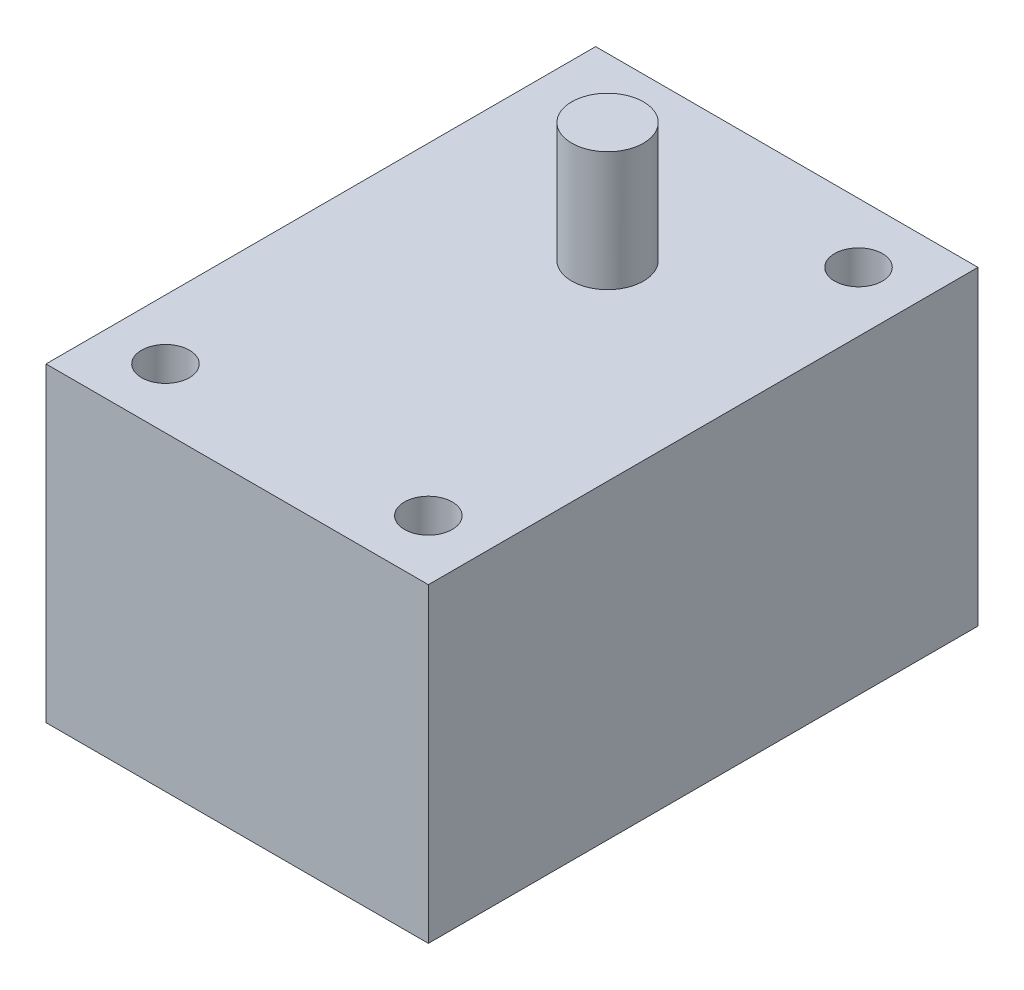
from build123d import *

# Parameters (mm, degrees)
SKETCH2_W            = 32
SKETCH2_H            = 26
BASE_DEPTH           = 46
SKETCH3_R            = 2
MOUNTING_HOLES_DEPTH = 10
SKETCH4_R            = 3
AXLE_DEPTH           = 10


with BuildPart() as part:
    # Sketch2 → base (new body)
    with BuildSketch(Plane.XY):
        with Locations((16, 13)):
            Rectangle(SKETCH2_W, SKETCH2_H)
    extrude(amount=BASE_DEPTH)

    # Sketch3 → mounting holes (cut)
    with BuildSketch(Plane(origin=(0, 26, 0), x_dir=(1, 0, 0), z_dir=(0, 1, 0))):
        with Locations((5, -5)):
            Circle(SKETCH3_R)
        with Locations((27, -5)):
            Circle(SKETCH3_R)
        with Locations((27, -41)):
            Circle(SKETCH3_R)
        with Locations((5, -41)):
            Circle(SKETCH3_R)
    extrude(amount=-MOUNTING_HOLES_DEPTH, mode=Mode.SUBTRACT)

    # Sketch4 → axle (add)
    with BuildSketch(Plane(origin=(0, 26, 0), x_dir=(1, 0, 0), z_dir=(0, 1, 0))):
        with Locations((16, -15)):
            Circle(SKETCH4_R)
    extrude(amount=AXLE_DEPTH)


solid = part.part
